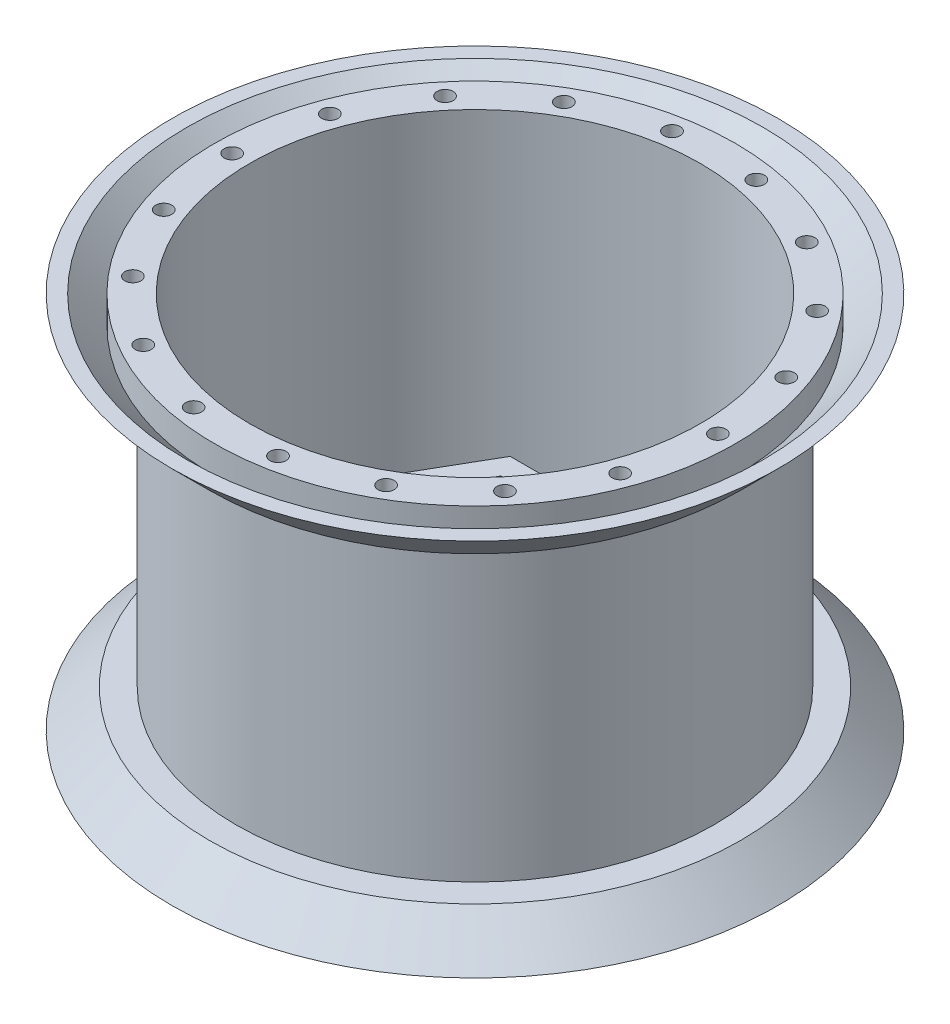
from build123d import *

# Parameters (mm, degrees)
BOSS_EXTRUDE1_DEPTH = 5
SKETCH3_RX          = 8.5
SKETCH3_RY          = 7.5
CUT_EXTRUDE1_DEPTH  = 71.5
SKETCH4_R           = 1.5
CUT_EXTRUDE2_DEPTH  = 5


with BuildPart() as part:
    # Sketch1 → Revolve1 (revolve)
    with BuildSketch(Plane(origin=(0, 0, 0), x_dir=(0, 0, -1), z_dir=(1, 0, 0))):
        Polygon((56.5, 0), (54.5, 0), (53.671572875, 0), (48.5, 5.171572875), (48.5, 0), (42, 0), (42, 5), (19, 21), (15, 21), (15, 25), (9, 25), (9, 27), (17, 27), (17, 23), (19.627231432, 23), (42, 7.436334909), (42, 70.5), (48.5, 70.5), (48.5, 65.328427125), (53.671572875, 70.5), (54.5, 70.5), (56.5, 70.5), (49.5, 63.5), (44.5, 63.5), (44.5, 7), (49.5, 7), align=None)
    revolve(axis=Axis((0, 0, 0), (0, 1, 0)))

    # Sketch2 → Boss-Extrude1 (add)
    with BuildSketch(Plane(origin=(0, 27, 0), x_dir=(1, 0, 0), z_dir=(0, 1, 0))):
        Polygon((8.948929172, -15.5), (17.897858345, 0), (8.948929172, 15.5), (-8.948929172, 15.5), (-17.897858345, 0), (-8.948929172, -15.5), align=None)
        Polygon((13.279056191, 0), (6.639528096, 11.5), (-6.639528096, 11.5), (-13.279056191, 0), (-6.639528096, -11.5), (6.639528096, -11.5), align=None, mode=Mode.SUBTRACT)
    extrude(amount=BOSS_EXTRUDE1_DEPTH)

    # Sketch3 → Cut-Extrude1 (cut, through all)
    with BuildSketch(Plane.XZ):
        with Locations(Location((30.5, 0), (0, 0, 0))):
            Ellipse(SKETCH3_RX, SKETCH3_RY)
        with Locations(Location((21.566756826, -21.566756826), (0, 0, -45))):
            Ellipse(SKETCH3_RX, SKETCH3_RY)
        with Locations(Location((0, -30.5), (0, 0, -90))):
            Ellipse(SKETCH3_RX, SKETCH3_RY)
        with Locations(Location((-21.566756826, -21.566756826), (0, 0, 45))):
            Ellipse(SKETCH3_RX, SKETCH3_RY)
        with Locations(Location((-30.5, 0), (0, 0, 180))):
            Ellipse(SKETCH3_RX, SKETCH3_RY)
        with Locations(Location((-21.566756826, 21.566756826), (0, 0, -45))):
            Ellipse(SKETCH3_RX, SKETCH3_RY)
        with Locations(Location((0, 30.5), (0, 0, 90))):
            Ellipse(SKETCH3_RX, SKETCH3_RY)
        with Locations(Location((21.566756826, 21.566756826), (0, 0, 45))):
            Ellipse(SKETCH3_RX, SKETCH3_RY)
    extrude(amount=-CUT_EXTRUDE1_DEPTH, mode=Mode.SUBTRACT)

    # Sketch4 → Cut-Extrude2 (cut)
    with BuildSketch(Plane.XZ):
        with Locations((45.25, 0)):
            Circle(SKETCH4_R)
        with Locations((42.521091091, -15.476411485)):
            Circle(SKETCH4_R)
        with Locations((34.663511051, -29.086139338)):
            Circle(SKETCH4_R)
        with Locations((22.625, -39.187649521)):
            Circle(SKETCH4_R)
        with Locations((7.857580039, -44.562550824)):
            Circle(SKETCH4_R)
        with Locations((-7.857580039, -44.562550824)):
            Circle(SKETCH4_R)
        with Locations((-22.625, -39.187649521)):
            Circle(SKETCH4_R)
        with Locations((-34.663511051, -29.086139338)):
            Circle(SKETCH4_R)
        with Locations((-42.521091091, -15.476411485)):
            Circle(SKETCH4_R)
        with Locations((-45.25, 0)):
            Circle(SKETCH4_R)
        with Locations((-42.521091091, 15.476411485)):
            Circle(SKETCH4_R)
        with Locations((-34.663511051, 29.086139338)):
            Circle(SKETCH4_R)
        with Locations((-22.625, 39.187649521)):
            Circle(SKETCH4_R)
        with Locations((-7.857580039, 44.562550824)):
            Circle(SKETCH4_R)
        with Locations((7.857580039, 44.562550824)):
            Circle(SKETCH4_R)
        with Locations((22.625, 39.187649521)):
            Circle(SKETCH4_R)
        with Locations((34.663511051, 29.086139338)):
            Circle(SKETCH4_R)
        with Locations((42.521091091, 15.476411485)):
            Circle(SKETCH4_R)
    cut_extrude2 = extrude(amount=-CUT_EXTRUDE2_DEPTH, mode=Mode.SUBTRACT)

    # Mirror1: Cut-Extrude2 across plane
    add(cut_extrude2.mirror(Plane(origin=(0, 35.25, 0), x_dir=(0, 0, 1), z_dir=(0, -1, 0))), mode=Mode.SUBTRACT)


solid = part.part
